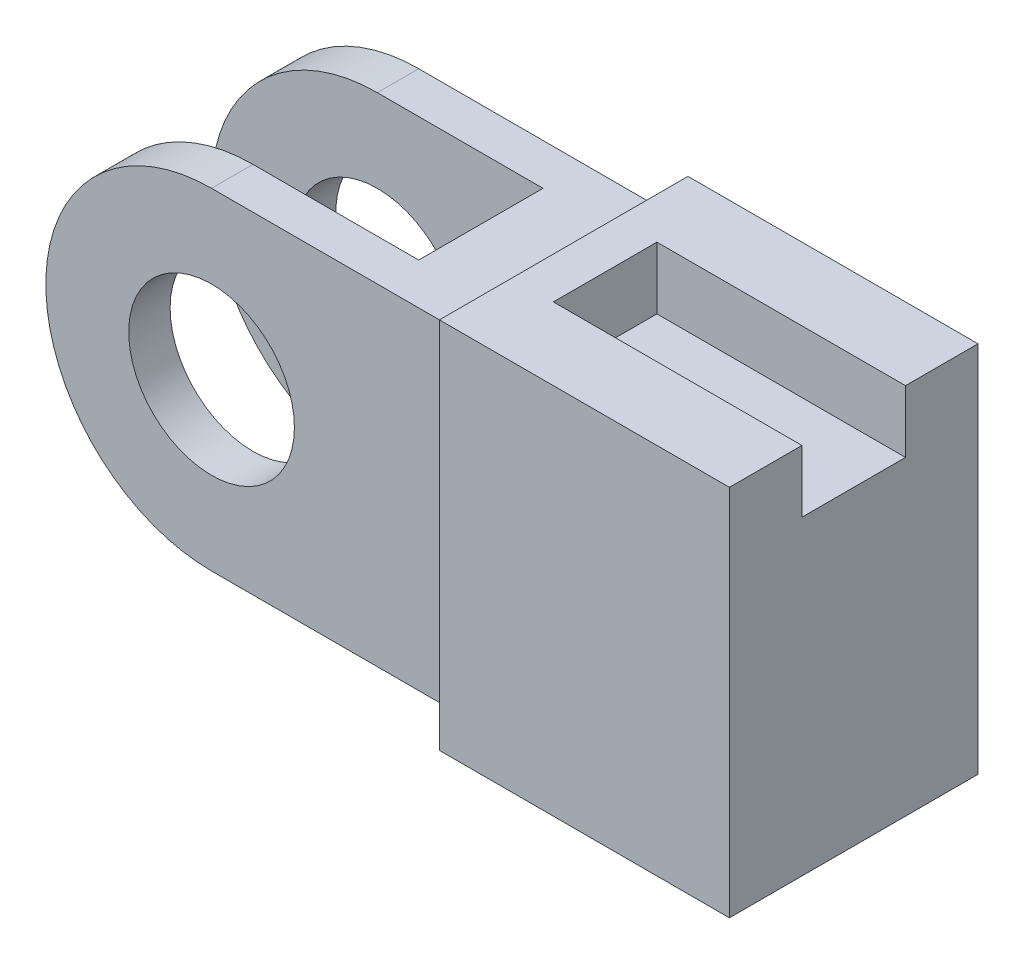
from build123d import *

# Parameters (mm, degrees)
BOSS_EXTRUDE1_DEPTH = 25
SKETCH2_R           = 20
CUT_EXTRUDE1_DEPTH  = 51
SKETCH3_W           = 80
SKETCH3_H           = 80
CUT_EXTRUDE2_DEPTH  = 15
SKETCH4_W           = 60
SKETCH4_H           = 90
BOSS_EXTRUDE2_DEPTH = 70
SKETCH5_W           = 25
SKETCH5_H           = 15
CUT_EXTRUDE3_DEPTH  = 60


with BuildPart() as part:
    # Sketch1 → Boss-Extrude1 (new body, symmetric)
    with BuildSketch(Plane.XY):
        with BuildLine():
            Line((-60, 0), (0, 0))
            Line((0, 0), (0, 80))
            Line((0, 80), (-60, 80))
            ThreePointArc((-60, 80), (-88.284271217, 68.284271278), (-100, 40.000000086))
            ThreePointArc((-100, 40.000000086), (-88.284271278, 11.715728783), (-60, 0))
        make_face()
    extrude(amount=BOSS_EXTRUDE1_DEPTH, both=True)

    # Sketch2 → Cut-Extrude1 (cut, through all)
    with BuildSketch(Plane.XY.offset(25)):
        with Locations((-60, 40)):
            Circle(SKETCH2_R)
    extrude(amount=-CUT_EXTRUDE1_DEPTH, mode=Mode.SUBTRACT)

    # Sketch3 → Cut-Extrude2 (cut, symmetric)
    with BuildSketch(Plane.XY):
        with Locations((-60, 40)):
            Rectangle(SKETCH3_W, SKETCH3_H)
    extrude(amount=CUT_EXTRUDE2_DEPTH, both=True, mode=Mode.SUBTRACT)

    # Sketch4 → Boss-Extrude2 (add)
    with BuildSketch(Plane(origin=(0, 0, 0), x_dir=(0, 0, -1), z_dir=(1, 0, 0))):
        with Locations((0, 40)):
            Rectangle(SKETCH4_W, SKETCH4_H)
    extrude(amount=BOSS_EXTRUDE2_DEPTH)

    # Sketch5 → Cut-Extrude3 (cut)
    with BuildSketch(Plane(origin=(70, 0, 0), x_dir=(0, 0, -1), z_dir=(1, 0, 0))):
        with Locations((0, 77.5)):
            Rectangle(SKETCH5_W, SKETCH5_H)
    extrude(amount=-CUT_EXTRUDE3_DEPTH, mode=Mode.SUBTRACT)


solid = part.part
